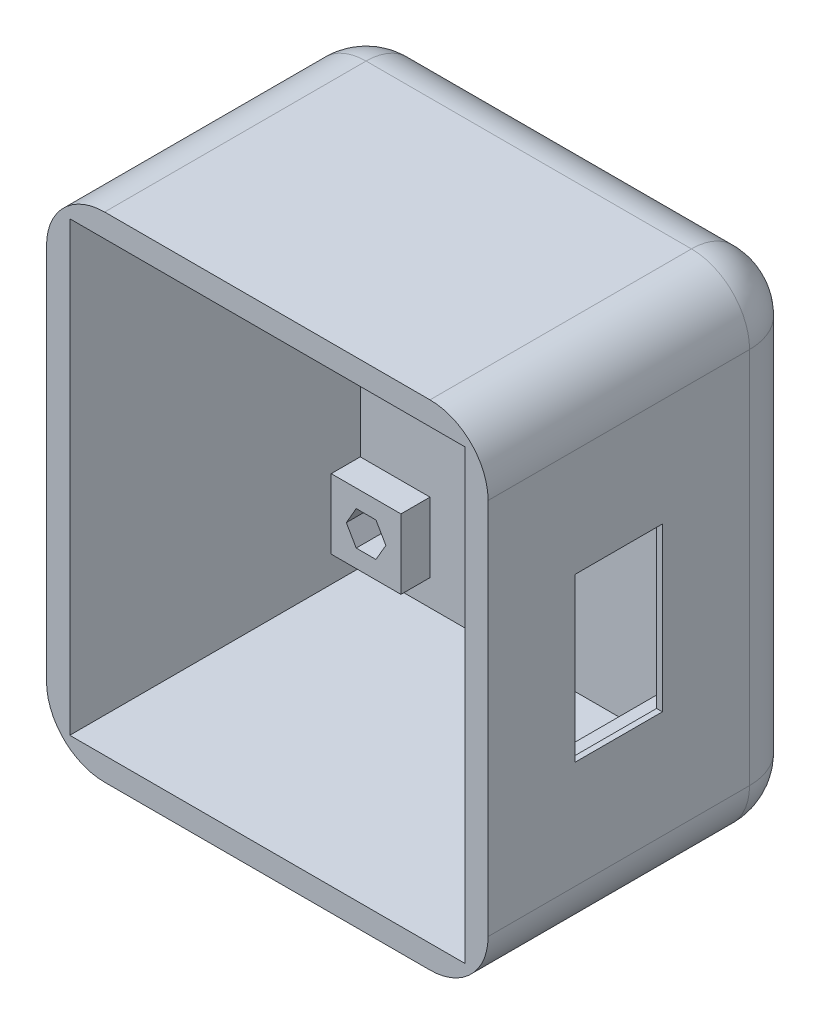
from build123d import *

# Parameters (mm, degrees)
CROQUIS1_W              = 76
CROQUIS1_H              = 85
SALIENTE_EXTRUIR1_DEPTH = 5
SALIENTE_EXTRUIR5_DEPTH = 5
CROQUIS6_W              = 76
CROQUIS6_H              = 85
CROQUIS6_W_2            = 68
CROQUIS6_H_2            = 77
SALIENTE_EXTRUIR6_DEPTH = 50
REDONDEO1_R             = 10
CROQUIS7_W              = 15
CROQUIS7_H              = 28
CORTAR_EXTRUIR2_DEPTH   = 5
CROQUIS8_W              = 30
CROQUIS8_H              = 30
CORTAR_EXTRUIR3_DEPTH   = 3
CROQUIS10_W             = 4
CROQUIS10_H             = 4
SALIENTE_EXTRUIR7_DEPTH = 1.5


with BuildPart() as part:
    # Croquis1 → Saliente-Extruir1 (new body)
    with BuildSketch(Plane.XY):
        Rectangle(CROQUIS1_W, CROQUIS1_H)
    extrude(amount=SALIENTE_EXTRUIR1_DEPTH)

    # Croquis5 → Saliente-Extruir5 (add)
    with BuildSketch(Plane.XY.offset(5)):
        Polygon((25.754700538, -30), (22, -30), (22, -34), (34, -34), (34, -22), (30, -22), (30, -25.575128869), (31.4, -28), (29.7, -30.944486373), (26.3, -30.944486373), align=None)
        Polygon((22, -22), (22, -30), (25.754700538, -30), (24.6, -28), (26.3, -25.055513627), (29.7, -25.055513627), (30, -25.575128869), (30, -22), align=None)
        Polygon((-22, -30), (-25.754700538, -30), (-26.3, -30.944486373), (-29.7, -30.944486373), (-31.4, -28), (-30, -25.575128869), (-30, -22), (-34, -22), (-34, -34), (-22, -34), align=None)
        Polygon((-24.6, -28), (-25.754700538, -30), (-22, -30), (-22, -22), (-30, -22), (-30, -25.575128869), (-29.7, -25.055513627), (-26.3, -25.055513627), align=None)
        Polygon((-30, 25.575128869), (-30, 22), (-22, 22), (-22, 30), (-25.754700538, 30), (-24.6, 28), (-26.3, 25.055513627), (-29.7, 25.055513627), align=None)
        Polygon((-34, 22), (-30, 22), (-30, 25.575128869), (-31.4, 28), (-29.7, 30.944486373), (-26.3, 30.944486373), (-25.754700538, 30), (-22, 30), (-22, 34), (-34, 34), align=None)
        Polygon((30, 25.575128869), (30, 22), (34, 22), (34, 34), (22, 34), (22, 30), (25.754700538, 30), (26.3, 30.944486373), (29.7, 30.944486373), (31.4, 28), align=None)
        Polygon((22, 22), (30, 22), (30, 25.575128869), (29.7, 25.055513627), (26.3, 25.055513627), (24.6, 28), (25.754700538, 30), (22, 30), align=None)
    extrude(amount=SALIENTE_EXTRUIR5_DEPTH)

    # Croquis6 → Saliente-Extruir6 (add)
    with BuildSketch(Plane.XY.offset(5)):
        Rectangle(CROQUIS6_W, CROQUIS6_H)
        Rectangle(CROQUIS6_W_2, CROQUIS6_H_2, mode=Mode.SUBTRACT)
    extrude(amount=SALIENTE_EXTRUIR6_DEPTH)

    # Redondeo1
    redondeo1_edges = [part.edges().sort_by_distance(p)[0] for p in [
        (0, 42.5, 0),
        (38, 0, 0),
        (0, -42.5, 0),
        (-38, 0, 0),
        (-38, 42.5, 27.5),
        (38, 42.5, 27.5),
        (38, -42.5, 27.5),
        (-38, -42.5, 27.5),
    ]]
    fillet(redondeo1_edges, radius=REDONDEO1_R)

    # Croquis7 → Cortar-Extruir2 (cut)
    with BuildSketch(Plane(origin=(38, 0, 0), x_dir=(0, 0, -1), z_dir=(1, 0, 0))):
        with Locations((-32.5, 0)):
            Rectangle(CROQUIS7_W, CROQUIS7_H)
    extrude(amount=-CORTAR_EXTRUIR2_DEPTH, mode=Mode.SUBTRACT)

    # Croquis8 → Cortar-Extruir3 (cut)
    with BuildSketch(Plane.ZY.offset(-34)):
        with Locations((34, 0)):
            Rectangle(CROQUIS8_W, CROQUIS8_H)
    extrude(amount=-CORTAR_EXTRUIR3_DEPTH, mode=Mode.SUBTRACT)

    # Croquis10 → Saliente-Extruir7 (add)
    with BuildSketch(Plane.ZY.offset(-37)):
        with Locations((21, -13)):
            Rectangle(CROQUIS10_W, CROQUIS10_H)
        with Locations((47, -13)):
            Rectangle(CROQUIS10_W, CROQUIS10_H)
        with Locations((47, 13)):
            Rectangle(CROQUIS10_W, CROQUIS10_H)
        with Locations((21, 13)):
            Rectangle(CROQUIS10_W, CROQUIS10_H)
    extrude(amount=SALIENTE_EXTRUIR7_DEPTH)


solid = part.part
